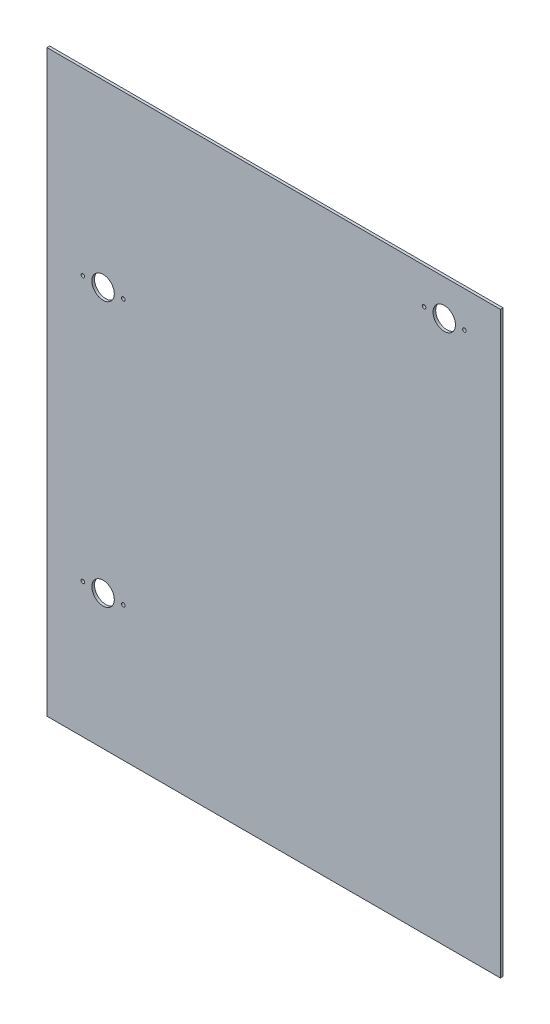
from build123d import *

# Parameters (mm, degrees)
SKICA1_W                = 505
SKICA1_H                = 645
SKICA1_R                = 2
SKICA1_R_2              = 12.5
P_IDAT_VYSUNUT_M1_DEPTH = 3


with BuildPart() as part:
    # Skica1 → Přidat vysunutím1 (new body)
    with BuildSketch(Plane.XY):
        Rectangle(SKICA1_W, SKICA1_H)
        with Locations((-212.5, -172.5)):
            Circle(SKICA1_R, mode=Mode.SUBTRACT)
        with Locations((-190, -172.5)):
            Circle(SKICA1_R_2, mode=Mode.SUBTRACT)
        with Locations((-167.5, -172.5)):
            Circle(SKICA1_R, mode=Mode.SUBTRACT)
        with Locations((-212.5, 122.5)):
            Circle(SKICA1_R, mode=Mode.SUBTRACT)
        with Locations((-190, 122.5)):
            Circle(SKICA1_R_2, mode=Mode.SUBTRACT)
        with Locations((-167.5, 122.5)):
            Circle(SKICA1_R, mode=Mode.SUBTRACT)
        with Locations((167.5, 282.5)):
            Circle(SKICA1_R, mode=Mode.SUBTRACT)
        with Locations((190, 282.5)):
            Circle(SKICA1_R_2, mode=Mode.SUBTRACT)
        with Locations((212.5, 282.5)):
            Circle(SKICA1_R, mode=Mode.SUBTRACT)
    extrude(amount=P_IDAT_VYSUNUT_M1_DEPTH)


solid = part.part
